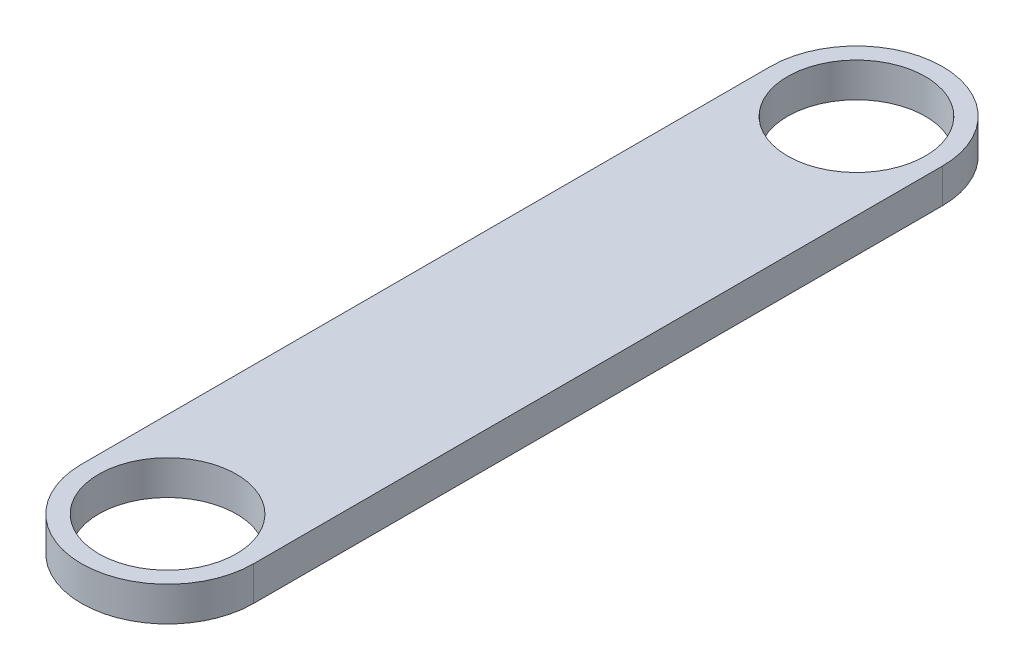
from build123d import *

# Parameters (mm, degrees)
SKETCH1_R           = 2
BOSS_EXTRUDE1_DEPTH = 1


with BuildPart() as part:
    # Sketch1 → Boss-Extrude1 (new body)
    with BuildSketch(Plane(origin=(0, 0, 0), x_dir=(1, 0, 0), z_dir=(0, 1, 0))):
        with BuildLine():
            Line((-2.5, 0), (-2.5, 20))
            ThreePointArc((-2.5, 20), (0, 22.5), (2.5, 20))
            Line((2.5, 20), (2.5, 0))
            ThreePointArc((2.5, 0), (0, -2.5), (-2.5, 0))
        make_face()
        Circle(SKETCH1_R, mode=Mode.SUBTRACT)
        with Locations((0, 20)):
            Circle(SKETCH1_R, mode=Mode.SUBTRACT)
    extrude(amount=BOSS_EXTRUDE1_DEPTH)


solid = part.part
